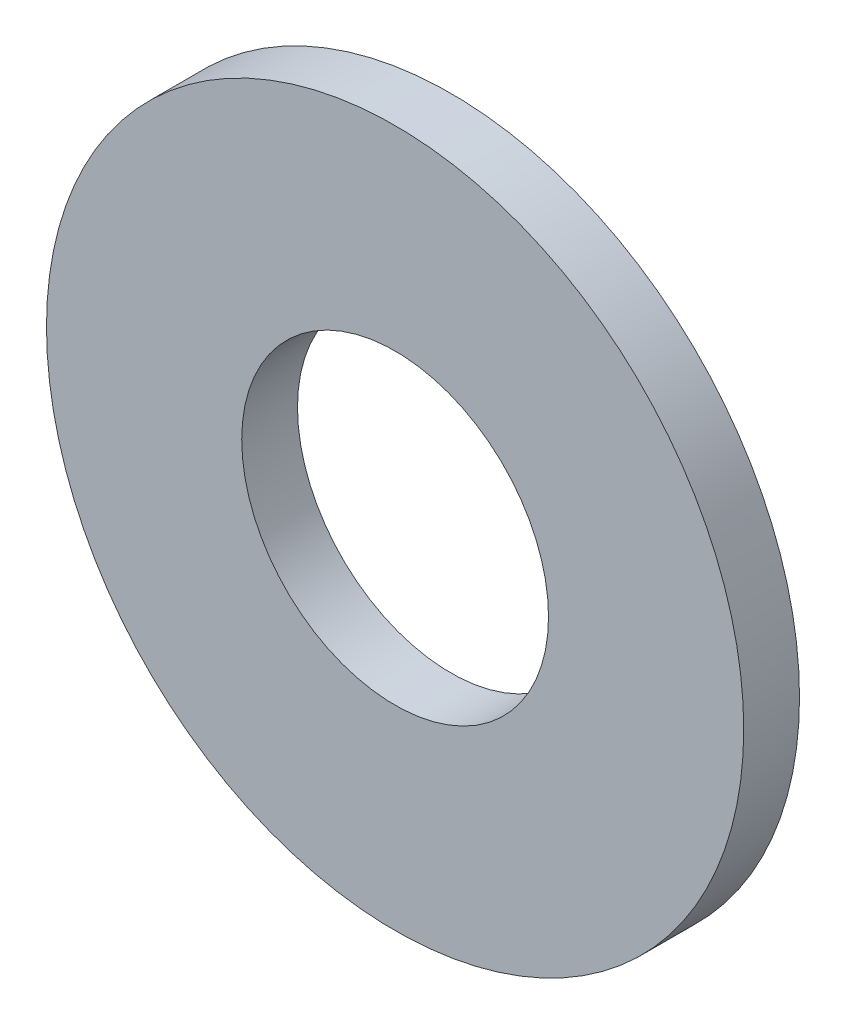
from build123d import *

# Parameters (mm, degrees)
SKETCH1_R           = 2.5
SKETCH1_R_2         = 1.1
BOSS_EXTRUDE1_DEPTH = 0.4


with BuildPart() as part:
    # Sketch1 → Boss-Extrude1 (new body)
    with BuildSketch(Plane.XY):
        Circle(SKETCH1_R)
        Circle(SKETCH1_R_2, mode=Mode.SUBTRACT)
    extrude(amount=BOSS_EXTRUDE1_DEPTH)


solid = part.part
